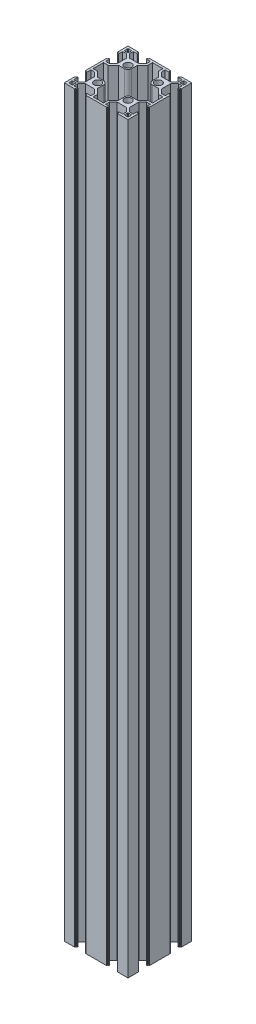
from build123d import *

# Parameters (mm, degrees)
SKETCH1_W                = 60
SKETCH1_H                = 60
BOSS_EXTRUDE1_DEPTH      = 700
CUT_EXTRUDE1_DEPTH       = 702.284535691
CIRPATTERN1_COUNT        = 4
CIRPATTERN1_COPY_1_DEPTH = 702.284535691
CIRPATTERN1_COPY_2_DEPTH = 702.284535691
CIRPATTERN1_COPY_3_DEPTH = 702.284535691
SKETCH4_R                = 3.4
CUT_EXTRUDE2_DEPTH       = 702.284535691
FILLET1_R                = 0.2
FILLET2_R                = 0.2
FILLET3_R                = 0.2
FILLET4_R                = 0.2


with BuildPart() as part:
    # Sketch1 → Boss-Extrude1 (new body)
    with BuildSketch(Plane(origin=(0, 0, 0), x_dir=(1, 0, 0), z_dir=(0, 1, 0))):
        Rectangle(SKETCH1_W, SKETCH1_H)
        Polygon((-23.05, -28), (-6.95, -28), (-6.95, -24.4), (-10.615, -20.8), (-19.385, -20.8), (-23.05, -24.4), align=None, mode=Mode.SUBTRACT)
        Polygon((10.615, -20.8), (19.385, -20.8), (23.05, -24.4), (23.05, -28), (6.95, -28), (6.95, -24.4), align=None, mode=Mode.SUBTRACT)
        Polygon((19.385, 20.8), (23.05, 24.4), (23.05, 28), (6.95, 28), (6.95, 24.4), (10.615, 20.8), align=None, mode=Mode.SUBTRACT)
        Polygon((-23.05, 24.4), (-23.05, 28), (-6.95, 28), (-6.95, 24.4), (-10.615, 20.8), (-19.385, 20.8), align=None, mode=Mode.SUBTRACT)
        Polygon((-20.8, 19.385), (-24.4, 23.05), (-28, 23.05), (-28, 6.95), (-24.4, 6.95), (-20.8, 10.615), align=None, mode=Mode.SUBTRACT)
        Polygon((-24.4, -23.05), (-28, -23.05), (-28, -6.95), (-24.4, -6.95), (-20.8, -10.615), (-20.8, -19.385), align=None, mode=Mode.SUBTRACT)
        Polygon((20.8, -19.385), (24.4, -23.05), (28, -23.05), (28, -6.95), (24.4, -6.95), (20.8, -10.615), align=None, mode=Mode.SUBTRACT)
        Polygon((24.4, 23.05), (28, 23.05), (28, 6.95), (24.4, 6.95), (20.8, 10.615), (20.8, 19.385), align=None, mode=Mode.SUBTRACT)
    extrude(amount=BOSS_EXTRUDE1_DEPTH)

    # Sketch2 → Cut-Extrude1 (cut, through all)
    with BuildSketch(Plane(origin=(0, 700, 0), x_dir=(1, 0, 0), z_dir=(0, 1, 0))):
        Polygon((-19.1, -28), (-19.1, -29), (-20.1, -29), (-20.1, -30), (-9.9, -30), (-9.9, -29), (-10.9, -29), (-10.9, -28), align=None)
    cut_extrude1 = extrude(amount=-CUT_EXTRUDE1_DEPTH, mode=Mode.SUBTRACT)

    # Mirror1: Cut-Extrude1 across plane
    add(cut_extrude1.mirror(Plane(origin=(0, 0, 0), x_dir=(0, 0, 1), z_dir=(1, 0, 0))), mode=Mode.SUBTRACT)

    # CirPattern1: Cut-Extrude1 ×4 about axis
    cirpattern1_axis = Axis((0, 1050, 0), (0, -1, 0))
    for i in range(1, CIRPATTERN1_COUNT):
        add(cut_extrude1.rotate(cirpattern1_axis, i * 360 / CIRPATTERN1_COUNT), mode=Mode.SUBTRACT)

    # CirPattern1 copy 1 sketch → CirPattern1 copy 1 (cut, through all)
    with BuildSketch(Plane(origin=(0, 700, 0), x_dir=(0, 0, -1), z_dir=(0, 1, 0))):
        Polygon((-19.1, 28), (-19.1, 29), (-20.1, 29), (-20.1, 30), (-9.9, 30), (-9.9, 29), (-10.9, 29), (-10.9, 28), align=None)
    extrude(amount=-CIRPATTERN1_COPY_1_DEPTH, mode=Mode.SUBTRACT)

    # CirPattern1 copy 2 sketch → CirPattern1 copy 2 (cut, through all)
    with BuildSketch(Plane(origin=(0, 700, 0), x_dir=(1, 0, 0), z_dir=(0, 1, 0))):
        Polygon((-19.1, 28), (-19.1, 29), (-20.1, 29), (-20.1, 30), (-9.9, 30), (-9.9, 29), (-10.9, 29), (-10.9, 28), align=None)
    extrude(amount=-CIRPATTERN1_COPY_2_DEPTH, mode=Mode.SUBTRACT)

    # CirPattern1 copy 3 sketch → CirPattern1 copy 3 (cut, through all)
    with BuildSketch(Plane.ZX.offset(700)):
        Polygon((-19.1, 28), (-19.1, 29), (-20.1, 29), (-20.1, 30), (-9.9, 30), (-9.9, 29), (-10.9, 29), (-10.9, 28), align=None)
    extrude(amount=-CIRPATTERN1_COPY_3_DEPTH, mode=Mode.SUBTRACT)

    # Sketch4 → Cut-Extrude2 (cut, through all)
    with BuildSketch(Plane(origin=(0, 700, 0), x_dir=(1, 0, 0), z_dir=(0, 1, 0))):
        with BuildLine():
            Line((-13.197035349, 9.797035349), (-18.8, 9.797035349))
            Line((-18.8, 9.797035349), (-23.561071557, 4.95))
            Line((-23.561071557, 4.95), (-28, 4.95))
            Line((-28, 4.95), (-28, -4.95))
            Line((-28, -4.95), (-23.561071557, -4.95))
            Line((-23.561071557, -4.95), (-18.8, -9.797035349))
            Line((-18.8, -9.797035349), (-13.197035349, -9.797035349))
            ThreePointArc((-13.197035349, -9.797035349), (-10.792872293, -10.792872293), (-9.797035349, -13.197035349))
            Line((-9.797035349, -13.197035349), (-9.797035349, -18.8))
            Line((-9.797035349, -18.8), (-4.95, -23.561071557))
            Line((-4.95, -23.561071557), (-4.95, -28))
            Line((-4.95, -28), (4.95, -28))
            Line((4.95, -28), (4.95, -23.561071557))
            Line((4.95, -23.561071557), (9.797035349, -18.8))
            Line((9.797035349, -18.8), (9.797035349, -13.197035349))
            ThreePointArc((9.797035349, -13.197035349), (10.792872293, -10.792872293), (13.197035349, -9.797035349))
            Line((13.197035349, -9.797035349), (18.8, -9.797035349))
            Line((18.8, -9.797035349), (23.561071557, -4.95))
            Line((23.561071557, -4.95), (28, -4.95))
            Line((28, -4.95), (28, 4.95))
            Line((28, 4.95), (23.561071557, 4.95))
            Line((23.561071557, 4.95), (18.8, 9.797035349))
            Line((18.8, 9.797035349), (13.197035349, 9.797035349))
            ThreePointArc((13.197035349, 9.797035349), (10.792872293, 10.792872293), (9.797035349, 13.197035349))
            Line((9.797035349, 13.197035349), (9.797035349, 18.8))
            Line((9.797035349, 18.8), (4.95, 23.561071557))
            Line((4.95, 23.561071557), (4.95, 28))
            Line((4.95, 28), (-4.95, 28))
            Line((-4.95, 28), (-4.95, 23.561071557))
            Line((-4.95, 23.561071557), (-9.797035349, 18.8))
            Line((-9.797035349, 18.8), (-9.797035349, 13.197035349))
            ThreePointArc((-9.797035349, 13.197035349), (-10.792872293, 10.792872293), (-13.197035349, 9.797035349))
        make_face()
        with BuildLine():
            ThreePointArc((-28, -27.5), (-27.853553391, -27.853553391), (-27.5, -28))
            Line((-27.5, -28), (-24.9, -28))
            ThreePointArc((-24.9, -28), (-24.546446609, -27.853553391), (-24.4, -27.5))
            Line((-24.4, -27.5), (-24.4, -24.9))
            ThreePointArc((-24.4, -24.9), (-24.546446609, -24.546446609), (-24.9, -24.4))
            Line((-24.9, -24.4), (-27.5, -24.4))
            ThreePointArc((-27.5, -24.4), (-27.853553391, -24.546446609), (-28, -24.9))
            Line((-28, -24.9), (-28, -27.5))
        make_face()
        with BuildLine():
            ThreePointArc((24.4, -27.5), (24.546446609, -27.853553391), (24.9, -28))
            Line((24.9, -28), (27.5, -28))
            ThreePointArc((27.5, -28), (27.853553391, -27.853553391), (28, -27.5))
            Line((28, -27.5), (28, -24.9))
            ThreePointArc((28, -24.9), (27.853553391, -24.546446609), (27.5, -24.4))
            Line((27.5, -24.4), (24.9, -24.4))
            ThreePointArc((24.9, -24.4), (24.546446609, -24.546446609), (24.4, -24.9))
            Line((24.4, -24.9), (24.4, -27.5))
        make_face()
        with BuildLine():
            ThreePointArc((-27.5, 28), (-27.853553391, 27.853553391), (-28, 27.5))
            Line((-28, 27.5), (-28, 24.9))
            ThreePointArc((-28, 24.9), (-27.853553391, 24.546446609), (-27.5, 24.4))
            Line((-27.5, 24.4), (-24.9, 24.4))
            ThreePointArc((-24.9, 24.4), (-24.546446609, 24.546446609), (-24.4, 24.9))
            Line((-24.4, 24.9), (-24.4, 27.5))
            ThreePointArc((-24.4, 27.5), (-24.546446609, 27.853553391), (-24.9, 28))
            Line((-24.9, 28), (-27.5, 28))
        make_face()
        with BuildLine():
            ThreePointArc((28, 27.5), (27.853553391, 27.853553391), (27.5, 28))
            Line((27.5, 28), (24.9, 28))
            ThreePointArc((24.9, 28), (24.546446609, 27.853553391), (24.4, 27.5))
            Line((24.4, 27.5), (24.4, 24.9))
            ThreePointArc((24.4, 24.9), (24.546446609, 24.546446609), (24.9, 24.4))
            Line((24.9, 24.4), (27.5, 24.4))
            ThreePointArc((27.5, 24.4), (27.853553391, 24.546446609), (28, 24.9))
            Line((28, 24.9), (28, 27.5))
        make_face()
        with Locations((14.298517674, 14.298517674)):
            Circle(SKETCH4_R)
        with Locations((14.298517674, -14.298517674)):
            Circle(SKETCH4_R)
        with Locations((-14.298517674, -14.298517674)):
            Circle(SKETCH4_R)
        with Locations((-14.298517674, 14.298517674)):
            Circle(SKETCH4_R)
    extrude(amount=-CUT_EXTRUDE2_DEPTH, mode=Mode.SUBTRACT)

    # Fillet1
    fillet1_edges = [part.edges().sort_by_distance(p)[0] for p in [
        (28, 350, -19.1),
        (30, 350, -20.1),
        (29, 350, -20.1),
        (29, 350, -19.1),
        (28, 350, 10.9),
        (29, 350, 9.9),
        (28, 350, 19.1),
        (29, 350, 20.1),
        (30, 350, 20.1),
        (29, 350, 19.1),
        (29, 350, 10.9),
        (30, 350, 9.9),
        (30, 350, -9.9),
        (29, 350, -9.9),
        (29, 350, -10.9),
        (28, 350, -10.9),
    ]]
    fillet(fillet1_edges, radius=FILLET1_R)

    # Fillet2
    fillet2_edges = [part.edges().sort_by_distance(p)[0] for p in [
        (-20.1, 0, -29.5),
        (-20.1, 700, -29.5),
        (-20.1, 350, -29),
        (-19.6, 0, -29),
        (-19.1, 350, -29),
        (-19.6, 700, -29),
        (-9.9, 350, -30),
        (-10.9, 350, -28),
        (-10.9, 350, -29),
        (-9.9, 350, -29),
        (19.1, 350, -28),
        (19.1, 350, -29),
        (20.1, 350, -29),
        (20.1, 350, -30),
        (10.9, 350, -28),
        (10.9, 350, -29),
        (9.9, 350, -29),
        (9.9, 350, -30),
        (-19.1, 350, -28),
        (-20.1, 350, -30),
    ]]
    fillet(fillet2_edges, radius=FILLET2_R)

    # Fillet3
    fillet3_edges = [part.edges().sort_by_distance(p)[0] for p in [
        (-29, 350, 9.9),
        (-29, 350, -20.1),
        (-30, 350, -20.1),
        (-29, 350, -19.1),
        (-28, 350, -10.9),
        (-29, 350, -10.9),
        (-29, 350, -9.9),
        (-30, 350, -9.9),
        (-29, 350, 10.9),
        (-30, 350, 9.9),
        (-28, 350, 19.1),
        (-29, 350, 19.1),
        (-29, 350, 20.1),
        (-30, 350, 20.1),
    ]]
    fillet(fillet3_edges, radius=FILLET3_R)

    # Fillet4
    fillet4_edges = [part.edges().sort_by_distance(p)[0] for p in [
        (-19.1, 350, 28),
        (10.9, 350, 28),
        (19.1, 350, 28),
        (20.1, 350, 29),
        (-10.9, 350, 28),
        (-9.9, 350, 29),
        (9.9, 350, 29),
        (-20.1, 350, 29),
        (19.1, 350, 29),
        (20.1, 350, 30),
        (10.9, 350, 29),
        (9.9, 350, 30),
        (-9.9, 350, 30),
        (-10.9, 350, 29),
        (-19.1, 350, 29),
        (-20.1, 350, 30),
    ]]
    fillet(fillet4_edges, radius=FILLET4_R)


solid = part.part
